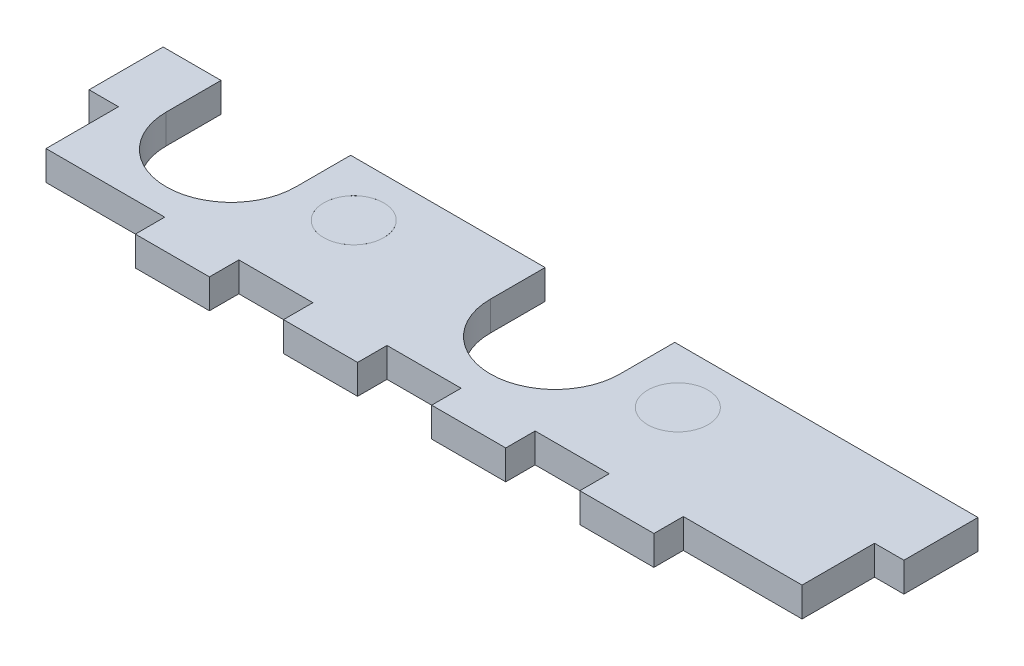
from build123d import *

# Parameters (mm, degrees)
SKETCH3_W             = 88
SKETCH3_H             = 30
BOSS_EXTRUDE1_DEPTH   = 3.175
CUT_EXTRUDE1_REACH    = 5.175
SKETCH4_W             = 3.175
SKETCH4_H             = 7.825
SKETCH4_W_2           = 8
SKETCH4_H_2           = 3.175
SKETCH4_H_3           = 11
CUT_EXTRUDE2_REACH    = 5.175
SKETCH5_R             = 3.25
CUT_EXTRUDE3_REACH    = 5.175
SKETCH6_W             = 81.65
SKETCH6_H             = 11
CUT_EXTRUDE4_REACH    = 5.175
SKETCH8_R             = 3.25
BOSS_EXTRUDE2_DEPTH   = 3.175
BOSS_EXTRUDE2_2_DEPTH = 3.175


with BuildPart() as part:
    # Sketch3 → Boss-Extrude1 (new body)
    with BuildSketch(Plane(origin=(0, 0, 0), x_dir=(1, 0, 0), z_dir=(0, 1, 0))):
        with Locations((44, -15)):
            Rectangle(SKETCH3_W, SKETCH3_H)
    extrude(amount=BOSS_EXTRUDE1_DEPTH)

    # Sketch4 → Cut-Extrude1 (cut, up to next)
    with BuildSketch(Plane(origin=(0, 3.175, 0), x_dir=(1, 0, 0), z_dir=(0, 1, 0)), mode=Mode.PRIVATE) as cut_extrude1_sk1:
        with Locations((1.5875, -22.9125)):
            Rectangle(SKETCH4_W, SKETCH4_H)
    cut_extrude1_tool1 = extrude(cut_extrude1_sk1.sketch, amount=-CUT_EXTRUDE1_REACH, mode=Mode.PRIVATE) & part.part
    add(cut_extrude1_tool1.solids().sort_by_distance((1.5875, 3.175, 22.9125))[0], mode=Mode.SUBTRACT)
    # Sketch4 → Cut-Extrude1 (cut, up to next)
    with BuildSketch(Plane(origin=(0, 3.175, 0), x_dir=(1, 0, 0), z_dir=(0, 1, 0)), mode=Mode.PRIVATE) as cut_extrude1_sk2:
        Polygon((0, -30), (16, -30), (16, -26.825), (3.175, -26.825), (0, -26.825), align=None)
    cut_extrude1_tool2 = extrude(cut_extrude1_sk2.sketch, amount=-CUT_EXTRUDE1_REACH, mode=Mode.PRIVATE) & part.part
    add(cut_extrude1_tool2.solids().sort_by_distance((8, 3.175, 28.4125))[0], mode=Mode.SUBTRACT)
    # Sketch4 → Cut-Extrude1 (cut, up to next)
    with BuildSketch(Plane(origin=(0, 3.175, 0), x_dir=(1, 0, 0), z_dir=(0, 1, 0)), mode=Mode.PRIVATE) as cut_extrude1_sk3:
        with Locations((28, -28.4125)):
            Rectangle(SKETCH4_W_2, SKETCH4_H_2)
    cut_extrude1_tool3 = extrude(cut_extrude1_sk3.sketch, amount=-CUT_EXTRUDE1_REACH, mode=Mode.PRIVATE) & part.part
    add(cut_extrude1_tool3.solids().sort_by_distance((28, 3.175, 28.4125))[0], mode=Mode.SUBTRACT)
    # Sketch4 → Cut-Extrude1 (cut, up to next)
    with BuildSketch(Plane(origin=(0, 3.175, 0), x_dir=(1, 0, 0), z_dir=(0, 1, 0)), mode=Mode.PRIVATE) as cut_extrude1_sk4:
        with Locations((44, -28.4125)):
            Rectangle(SKETCH4_W_2, SKETCH4_H_2)
    cut_extrude1_tool4 = extrude(cut_extrude1_sk4.sketch, amount=-CUT_EXTRUDE1_REACH, mode=Mode.PRIVATE) & part.part
    add(cut_extrude1_tool4.solids().sort_by_distance((44, 3.175, 28.4125))[0], mode=Mode.SUBTRACT)
    # Sketch4 → Cut-Extrude1 (cut, up to next)
    with BuildSketch(Plane(origin=(0, 3.175, 0), x_dir=(1, 0, 0), z_dir=(0, 1, 0)), mode=Mode.PRIVATE) as cut_extrude1_sk5:
        with Locations((60, -28.4125)):
            Rectangle(SKETCH4_W_2, SKETCH4_H_2)
    cut_extrude1_tool5 = extrude(cut_extrude1_sk5.sketch, amount=-CUT_EXTRUDE1_REACH, mode=Mode.PRIVATE) & part.part
    add(cut_extrude1_tool5.solids().sort_by_distance((60, 3.175, 28.4125))[0], mode=Mode.SUBTRACT)
    # Sketch4 → Cut-Extrude1 (cut, up to next)
    with BuildSketch(Plane(origin=(0, 3.175, 0), x_dir=(1, 0, 0), z_dir=(0, 1, 0)), mode=Mode.PRIVATE) as cut_extrude1_sk6:
        with Locations((86.4125, -22.9125)):
            Rectangle(SKETCH4_W, SKETCH4_H)
    cut_extrude1_tool6 = extrude(cut_extrude1_sk6.sketch, amount=-CUT_EXTRUDE1_REACH, mode=Mode.PRIVATE) & part.part
    add(cut_extrude1_tool6.solids().sort_by_distance((86.4125, 3.175, 22.9125))[0], mode=Mode.SUBTRACT)
    # Sketch4 → Cut-Extrude1 (cut, up to next)
    with BuildSketch(Plane(origin=(0, 3.175, 0), x_dir=(1, 0, 0), z_dir=(0, 1, 0)), mode=Mode.PRIVATE) as cut_extrude1_sk7:
        with Locations((86.4125, -5.5)):
            Rectangle(SKETCH4_W, SKETCH4_H_3)
    cut_extrude1_tool7 = extrude(cut_extrude1_sk7.sketch, amount=-CUT_EXTRUDE1_REACH, mode=Mode.PRIVATE) & part.part
    add(cut_extrude1_tool7.solids().sort_by_distance((86.4125, 3.175, 5.5))[0], mode=Mode.SUBTRACT)
    # Sketch4 → Cut-Extrude1 (cut, up to next)
    with BuildSketch(Plane(origin=(0, 3.175, 0), x_dir=(1, 0, 0), z_dir=(0, 1, 0)), mode=Mode.PRIVATE) as cut_extrude1_sk8:
        Polygon((72, -26.825), (72, -30), (88, -30), (88, -26.825), (84.825, -26.825), align=None)
    cut_extrude1_tool8 = extrude(cut_extrude1_sk8.sketch, amount=-CUT_EXTRUDE1_REACH, mode=Mode.PRIVATE) & part.part
    add(cut_extrude1_tool8.solids().sort_by_distance((80, 3.175, 28.4125))[0], mode=Mode.SUBTRACT)
    # Sketch4 → Cut-Extrude1 (cut, up to next)
    with BuildSketch(Plane(origin=(0, 3.175, 0), x_dir=(1, 0, 0), z_dir=(0, 1, 0)), mode=Mode.PRIVATE) as cut_extrude1_sk9:
        with Locations((1.5875, -5.5)):
            Rectangle(SKETCH4_W, SKETCH4_H_3)
    cut_extrude1_tool9 = extrude(cut_extrude1_sk9.sketch, amount=-CUT_EXTRUDE1_REACH, mode=Mode.PRIVATE) & part.part
    add(cut_extrude1_tool9.solids().sort_by_distance((1.5875, 3.175, 5.5))[0], mode=Mode.SUBTRACT)

    # Sketch5 → Cut-Extrude2 (cut, up to next)
    with BuildSketch(Plane(origin=(0, 3.175, 0), x_dir=(1, 0, 0), z_dir=(0, 1, 0)), mode=Mode.PRIVATE) as cut_extrude2_sk1:
        with Locations((61.5, -16.915)):
            Circle(SKETCH5_R)
    cut_extrude2_tool1 = extrude(cut_extrude2_sk1.sketch, amount=-CUT_EXTRUDE2_REACH, mode=Mode.PRIVATE) & part.part
    add(cut_extrude2_tool1.solids().sort_by_distance((61.5, 3.175, 16.915))[0], mode=Mode.SUBTRACT)
    # Sketch5 → Cut-Extrude2 (cut, up to next)
    with BuildSketch(Plane(origin=(0, 3.175, 0), x_dir=(1, 0, 0), z_dir=(0, 1, 0)), mode=Mode.PRIVATE) as cut_extrude2_sk2:
        with Locations((26.5, -16.915)):
            Circle(SKETCH5_R)
    cut_extrude2_tool2 = extrude(cut_extrude2_sk2.sketch, amount=-CUT_EXTRUDE2_REACH, mode=Mode.PRIVATE) & part.part
    add(cut_extrude2_tool2.solids().sort_by_distance((26.5, 3.175, 16.915))[0], mode=Mode.SUBTRACT)

    # Sketch6 → Cut-Extrude3 (cut, up to next)
    with BuildSketch(Plane(origin=(0, 3.175, 0), x_dir=(1, 0, 0), z_dir=(0, 1, 0)), mode=Mode.PRIVATE) as cut_extrude3_sk1:
        with Locations((44, -5.5)):
            Rectangle(SKETCH6_W, SKETCH6_H)
    cut_extrude3_tool1 = extrude(cut_extrude3_sk1.sketch, amount=-CUT_EXTRUDE3_REACH, mode=Mode.PRIVATE) & part.part
    add(cut_extrude3_tool1.solids().sort_by_distance((44, 3.175, 5.5))[0], mode=Mode.SUBTRACT)

    # Sketch7 → Cut-Extrude4 (cut, up to next)
    with BuildSketch(Plane(origin=(0, 3.175, 0), x_dir=(1, 0, 0), z_dir=(0, 1, 0)), mode=Mode.PRIVATE) as cut_extrude4_sk1:
        with BuildLine():
            Line((6.25, -16.915), (6.25, -11))
            Line((6.25, -11), (20.25, -11))
            Line((20.25, -11), (20.25, -16.915))
            ThreePointArc((20.25, -16.915), (13.25, -23.915), (6.25, -16.915))
        make_face()
    cut_extrude4_tool1 = extrude(cut_extrude4_sk1.sketch, amount=-CUT_EXTRUDE4_REACH, mode=Mode.PRIVATE) & part.part
    add(cut_extrude4_tool1.solids().sort_by_distance((13.25, 3.175, 16.813335))[0], mode=Mode.SUBTRACT)
    # Sketch7 → Cut-Extrude4 (cut, up to next)
    with BuildSketch(Plane(origin=(0, 3.175, 0), x_dir=(1, 0, 0), z_dir=(0, 1, 0)), mode=Mode.PRIVATE) as cut_extrude4_sk2:
        with BuildLine():
            Line((41.25, -16.915), (41.25, -11))
            Line((41.25, -11), (55.25, -11))
            Line((55.25, -11), (55.25, -16.915))
            ThreePointArc((55.25, -16.915), (48.25, -23.915), (41.25, -16.915))
        make_face()
    cut_extrude4_tool2 = extrude(cut_extrude4_sk2.sketch, amount=-CUT_EXTRUDE4_REACH, mode=Mode.PRIVATE) & part.part
    add(cut_extrude4_tool2.solids().sort_by_distance((48.25, 3.175, 16.813335))[0], mode=Mode.SUBTRACT)


with BuildPart() as body_2:
    # Sketch8 → Boss-Extrude2 (new body)
    with BuildSketch(Plane(origin=(0, 3.175, 0), x_dir=(1, 0, 0), z_dir=(0, 1, 0))):
        with Locations((26.5, -16.915)):
            Circle(SKETCH8_R)
    extrude(amount=-BOSS_EXTRUDE2_DEPTH)


with BuildPart() as body_3:
    # Sketch8 → Boss-Extrude2 2 (new body)
    with BuildSketch(Plane(origin=(0, 3.175, 0), x_dir=(1, 0, 0), z_dir=(0, 1, 0))):
        with Locations((61.5, -16.915)):
            Circle(SKETCH8_R)
    extrude(amount=-BOSS_EXTRUDE2_2_DEPTH)


solid = Compound([part.part, body_2.part, body_3.part])
